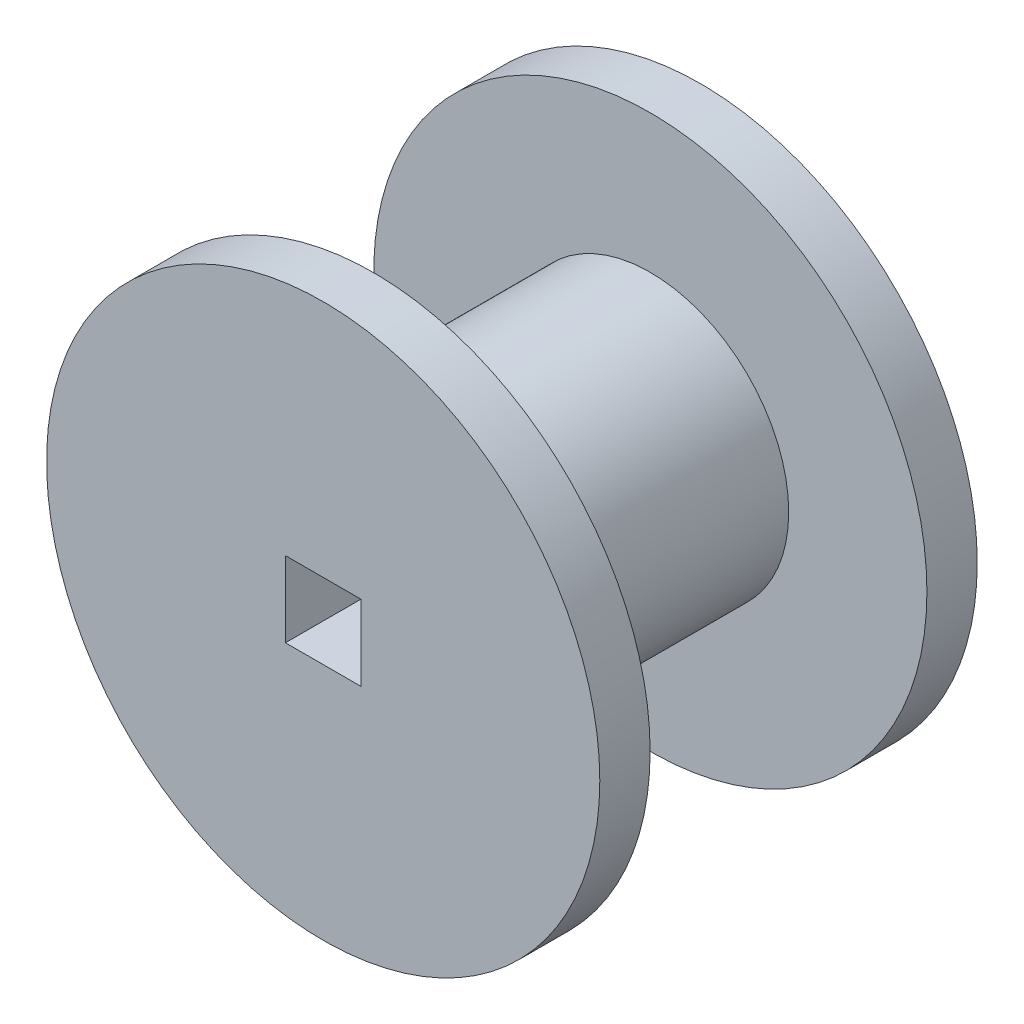
from build123d import *

# Parameters (mm, degrees)
SKETCH_1_R      = 10.992648621
SKETCH_1_W      = 3
SKETCH_1_H      = 3
EXTRUDE_1_DEPTH = 2
SKETCH_2_R      = 5.5
SKETCH_2_W      = 3
SKETCH_2_H      = 3
EXTRUDE_2_DEPTH = 5.5


with BuildPart() as part:
    # 草图1 → 凸台-拉伸1 (new body)
    with BuildSketch(Plane.XY):
        Circle(SKETCH_1_R)
        Rectangle(SKETCH_1_W, SKETCH_1_H, mode=Mode.SUBTRACT)
    extrude_1 = extrude(amount=EXTRUDE_1_DEPTH)

    # 草图2 → 凸台-拉伸2 (add)
    with BuildSketch(Plane.XY.offset(2)):
        Circle(SKETCH_2_R)
        Rectangle(SKETCH_2_W, SKETCH_2_H, mode=Mode.SUBTRACT)
    extrude_2 = extrude(amount=EXTRUDE_2_DEPTH)

    # 镜向1: 凸台-拉伸1, 凸台-拉伸2 across plane
    add(extrude_1.mirror(Plane.XY.offset(7.5)))
    add(extrude_2.mirror(Plane.XY.offset(7.5)))


solid = part.part
